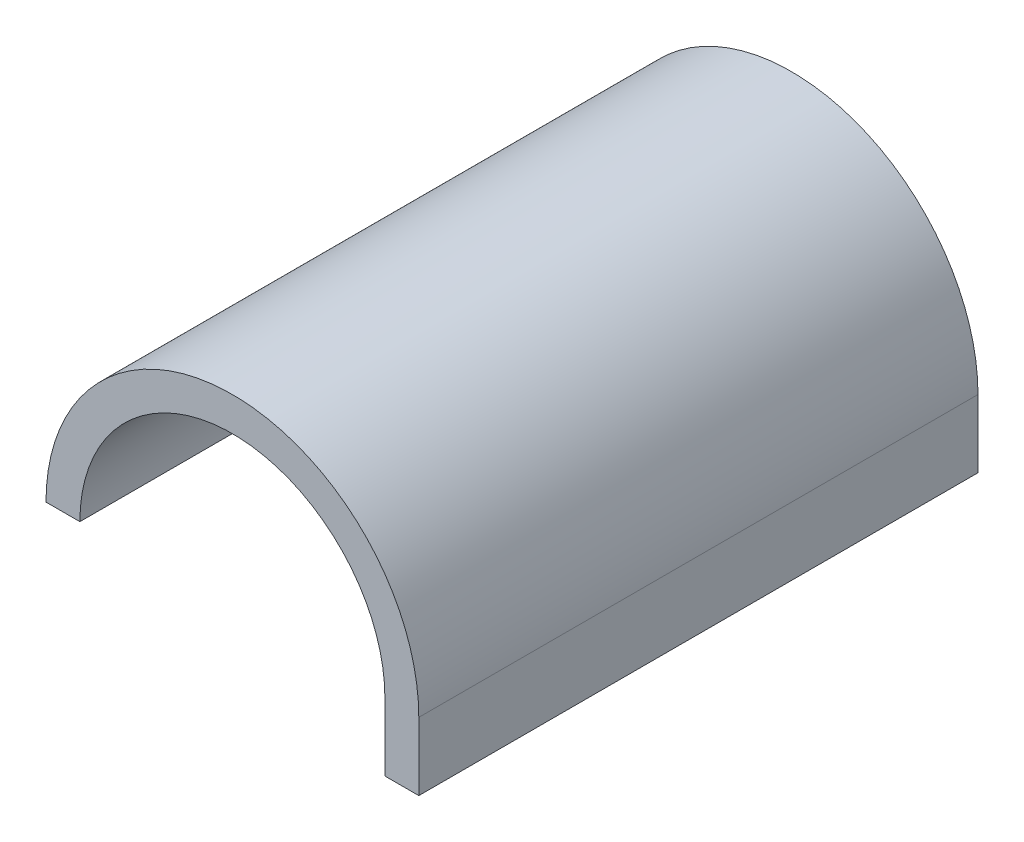
from build123d import *

# Parameters (mm, degrees)
BOSS_EXTRUDE1_DEPTH = 82.5
SKETCH3_W           = 10
SKETCH3_H           = 165
BOSS_EXTRUDE2_DEPTH = 20


with BuildPart() as part:
    # Sketch2 → Boss-Extrude1 (new body, symmetric)
    with BuildSketch(Plane.XY):
        with BuildLine():
            Line((-55, 0), (-45, 0))
            ThreePointArc((-45, 0), (0, 45), (45, 0))
            Line((45, 0), (55, 0))
            ThreePointArc((55, 0), (0, 55), (-55, 0))
        make_face()
    extrude(amount=BOSS_EXTRUDE1_DEPTH, both=True)

    # Sketch3 → Boss-Extrude2 (add)
    with BuildSketch(Plane.XZ):
        with Locations((50, 0)):
            Rectangle(SKETCH3_W, SKETCH3_H)
    extrude(amount=BOSS_EXTRUDE2_DEPTH)


solid = part.part
